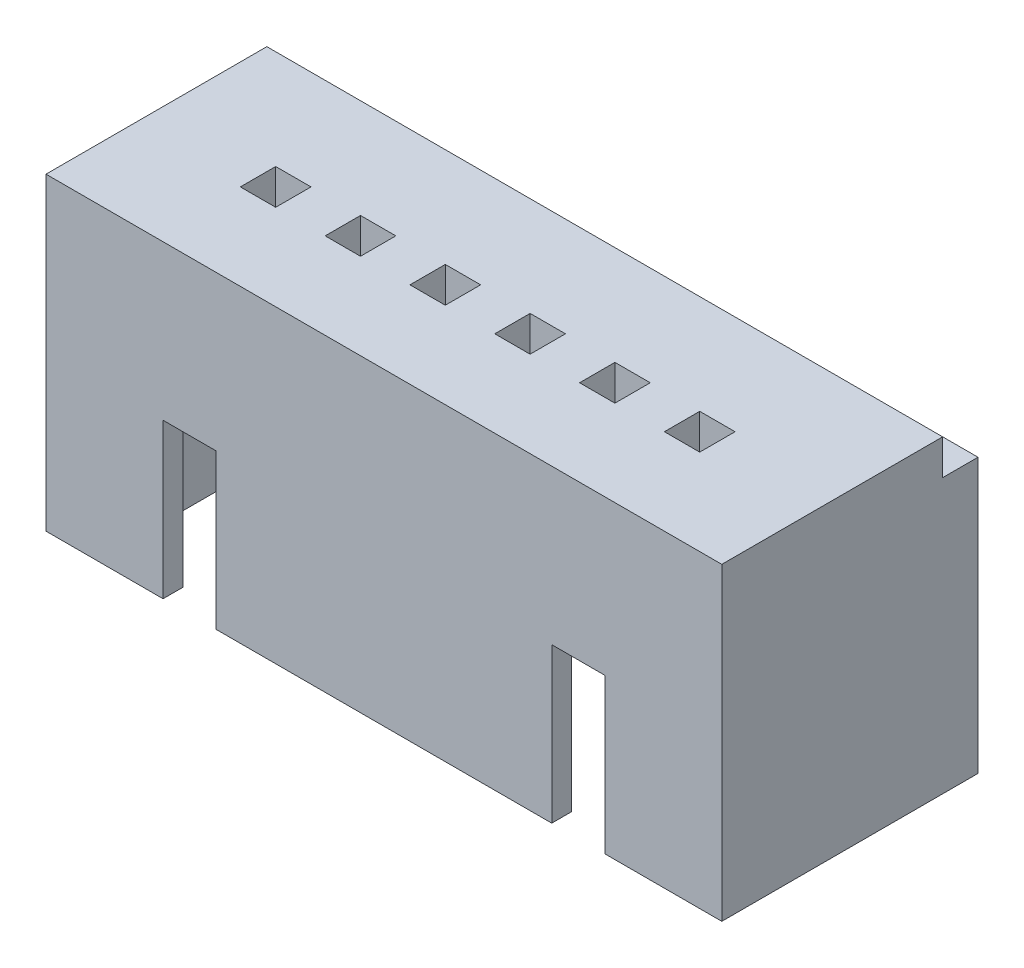
from build123d import *

# Parameters (mm, degrees)
SKETCH1_W           = 15.3
SKETCH1_H           = 5.8
BOSS_EXTRUDE1_DEPTH = 7
SKETCH3_W           = 13
SKETCH3_H           = 4.9
CUT_EXTRUDE1_DEPTH  = 5
SKETCH4_W           = 1.2
SKETCH4_H           = 3.5
CUT_EXTRUDE2_DEPTH  = 4
SKETCH5_W           = 15.3
SKETCH5_H           = 0.8
CUT_EXTRUDE3_DEPTH  = 0.8
SKETCH6_W           = 0.8
SKETCH6_H           = 0.8
CUT_EXTRUDE4_DEPTH  = 10
SKETCH7_W           = 13
SKETCH7_H           = 1
CUT_EXTRUDE5_DEPTH  = 0.3


with BuildPart() as part:
    # Sketch1 → Boss-Extrude1 (new body)
    with BuildSketch(Plane(origin=(0, 0, 0), x_dir=(1, 0, 0), z_dir=(0, 1, 0))):
        Rectangle(SKETCH1_W, SKETCH1_H)
    extrude(amount=BOSS_EXTRUDE1_DEPTH)

    # Sketch3 → Cut-Extrude1 (cut)
    with BuildSketch(Plane.XZ):
        Rectangle(SKETCH3_W, SKETCH3_H)
    extrude(amount=-CUT_EXTRUDE1_DEPTH, mode=Mode.SUBTRACT)

    # Sketch4 → Cut-Extrude2 (cut)
    with BuildSketch(Plane.XY.offset(2.9)):
        with Locations((-4.4, 1.75)):
            Rectangle(SKETCH4_W, SKETCH4_H)
        with Locations((4.4, 1.75)):
            Rectangle(SKETCH4_W, SKETCH4_H)
    extrude(amount=-CUT_EXTRUDE2_DEPTH, mode=Mode.SUBTRACT)

    # Sketch5 → Cut-Extrude3 (cut)
    with BuildSketch(Plane(origin=(0, 7, 0), x_dir=(1, 0, 0), z_dir=(0, 1, 0))):
        with Locations((0, 2.5)):
            Rectangle(SKETCH5_W, SKETCH5_H)
    extrude(amount=-CUT_EXTRUDE3_DEPTH, mode=Mode.SUBTRACT)

    # Sketch6 → Cut-Extrude4 (cut)
    with BuildSketch(Plane(origin=(0, 7, 0), x_dir=(1, 0, 0), z_dir=(0, 1, 0))):
        with Locations((4.8, -0.55)):
            Rectangle(SKETCH6_W, SKETCH6_H)
        with Locations((2.88, -0.55)):
            Rectangle(SKETCH6_W, SKETCH6_H)
        with Locations((0.96, -0.55)):
            Rectangle(SKETCH6_W, SKETCH6_H)
        with Locations((-0.96, -0.55)):
            Rectangle(SKETCH6_W, SKETCH6_H)
        with Locations((-2.88, -0.55)):
            Rectangle(SKETCH6_W, SKETCH6_H)
        with Locations((-4.8, -0.55)):
            Rectangle(SKETCH6_W, SKETCH6_H)
    extrude(amount=-CUT_EXTRUDE4_DEPTH, mode=Mode.SUBTRACT)

    # Sketch7 → Cut-Extrude5 (cut)
    with BuildSketch(Plane.XZ.offset(-5)):
        with Locations((0, -1.95)):
            Rectangle(SKETCH7_W, SKETCH7_H)
    extrude(amount=-CUT_EXTRUDE5_DEPTH, mode=Mode.SUBTRACT)


solid = part.part
